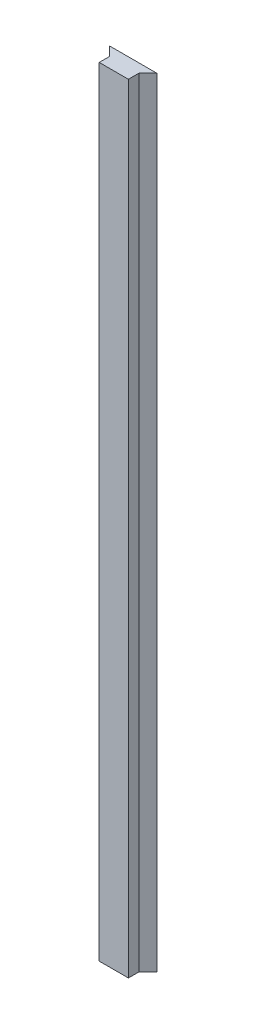
from build123d import *

# Parameters (mm, degrees)
BOSS_EXTRUDE1_DEPTH = 508


with BuildPart() as part:
    # Sketch1 → Boss-Extrude1 (new body)
    with BuildSketch(Plane(origin=(0, 0, 0), x_dir=(1, 0, 0), z_dir=(0, 1, 0))):
        Polygon((0, 0), (19.05, 0), (19.05, 6.858), (24.892, 12.7), (-5.842, 12.7), (0, 6.858), align=None)
    extrude(amount=BOSS_EXTRUDE1_DEPTH)


solid = part.part
